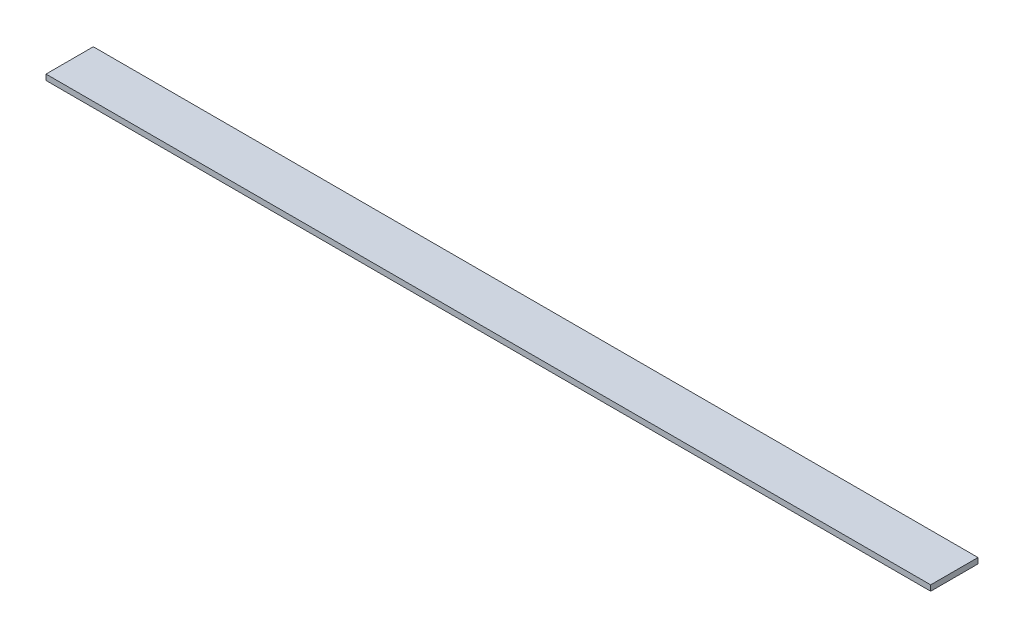
from build123d import *

# Parameters (mm, degrees)
SKETCH1_W           = 474.85
SKETCH1_H           = 25.4
BOSS_EXTRUDE1_DEPTH = 3


with BuildPart() as part:
    # Sketch1 → Boss-Extrude1 (new body)
    with BuildSketch(Plane(origin=(0, 334.925662842, 0), x_dir=(1, 0, 0), z_dir=(0, 1, 0))):
        with Locations((270.299872759, 58.017280325)):
            Rectangle(SKETCH1_W, SKETCH1_H)
    extrude(amount=BOSS_EXTRUDE1_DEPTH)


solid = part.part
